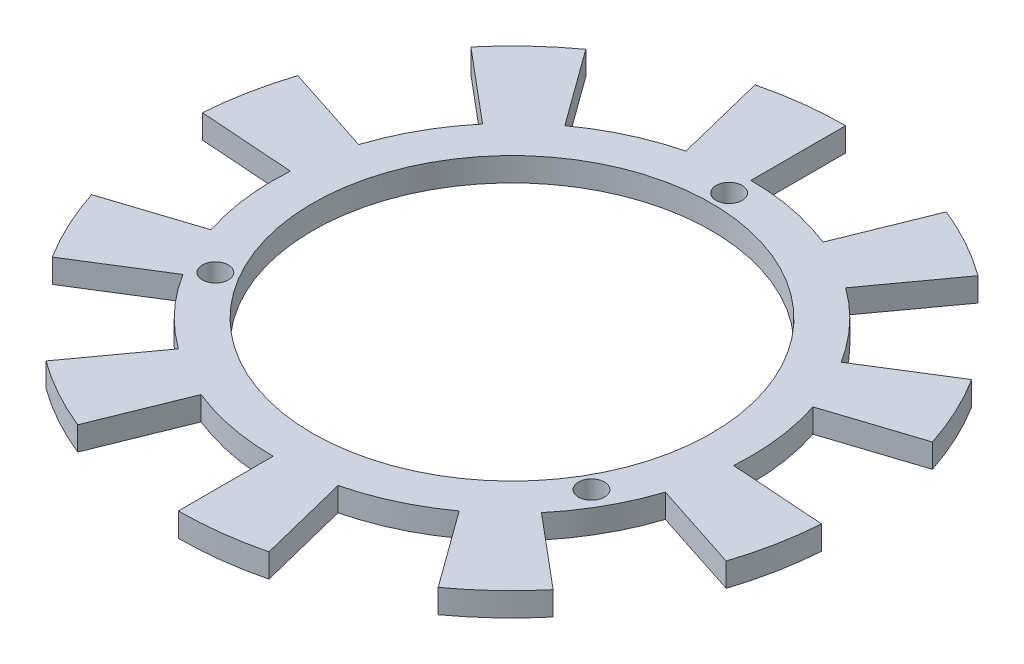
from build123d import *

# Parameters (mm, degrees)
SKETCH1_R           = 30.25
SKETCH1_R_2         = 25.25
EXTRUDE_THIN1_DEPTH = 3
SKETCH2_R           = 1.65
CUT_EXTRUDE3_DEPTH  = 10
BOSS_EXTRUDE1_DEPTH = 3


with BuildPart() as part:
    # Sketch1 → Extrude-Thin1 (new body)
    with BuildSketch(Plane(origin=(0, 0, 0), x_dir=(1, 0, 0), z_dir=(0, 1, 0))):
        Circle(SKETCH1_R)
        Circle(SKETCH1_R_2, mode=Mode.SUBTRACT)
    extrude(amount=-EXTRUDE_THIN1_DEPTH)

    # Sketch2 → Cut-Extrude3 (cut)
    with BuildSketch(Plane(origin=(0, 0, 0), x_dir=(1, 0, 0), z_dir=(0, 1, 0))):
        with Locations((0, 27.5)):
            Circle(SKETCH2_R)
        with Locations((23.815698604, -13.75)):
            Circle(SKETCH2_R)
        with Locations((-23.815698604, -13.75)):
            Circle(SKETCH2_R)
    extrude(amount=-CUT_EXTRUDE3_DEPTH, mode=Mode.SUBTRACT)

    # Sketch5 → Boss-Extrude1 (add)
    with BuildSketch(Plane.XZ.offset(3)):
        with BuildLine():
            Line((0, 42.25), (0, 30.25))
            ThreePointArc((0, 30.25), (3.686547638, 30.024521087), (7.318137342, 29.35144572))
            Line((7.318137342, 29.35144572), (10.221200089, 40.994994435))
            ThreePointArc((10.221200089, 40.994994435), (5.148979759, 41.935074907), (0, 42.25))
        make_face()
        with BuildLine():
            Line((24.833926909, 34.180968012), (17.780503882, 24.47276408))
            ThreePointArc((17.780503882, 24.47276408), (20.630450392, 22.123449474), (23.172844404, 19.444325193))
            Line((23.172844404, 19.444325193), (32.365377722, 27.157776509))
            ThreePointArc((32.365377722, 27.157776509), (28.814430713, 30.899693893), (24.833926909, 34.180968012))
        make_face()
        with BuildLine():
            Line((40.182137813, 13.055968012), (28.769459618, 9.34776408))
            ThreePointArc((28.769459618, 9.34776408), (29.694222299, 5.77197211), (30.17631252, 2.110133331))
            Line((30.17631252, 2.110133331), (42.147081123, 2.947211016))
            ThreePointArc((42.147081123, 2.947211016), (41.473748501, 8.061680055), (40.182137813, 13.055968012))
        make_face()
        with BuildLine():
            Line((40.182137813, -13.055968012), (28.769459618, -9.34776408))
            ThreePointArc((28.769459618, -9.34776408), (27.415810558, -12.784202418), (25.653454909, -16.030057743))
            Line((25.653454909, -16.030057743), (35.830032063, -22.389088914))
            ThreePointArc((35.830032063, -22.389088914), (38.291504002, -17.855621559), (40.182137813, -13.055968012))
        make_face()
        with BuildLine():
            Line((24.833926909, -34.180968012), (17.780503882, -24.47276408))
            ThreePointArc((17.780503882, -24.47276408), (14.665491012, -26.457246141), (11.331849451, -28.047311601))
            Line((11.331849451, -28.047311601), (15.827128572, -39.173517855))
            ThreePointArc((15.827128572, -39.173517855), (20.483206455, -36.952682627), (24.833926909, -34.180968012))
        make_face()
        with BuildLine():
            Line((0, -42.25), (0, -30.25))
            ThreePointArc((0, -30.25), (-3.686547638, -30.024521087), (-7.318137342, -29.35144572))
            Line((-7.318137342, -29.35144572), (-10.221200089, -40.994994435))
            ThreePointArc((-10.221200089, -40.994994435), (-5.148979759, -41.935074907), (0, -42.25))
        make_face()
        with BuildLine():
            Line((-24.833926909, -34.180968012), (-17.780503882, -24.47276408))
            ThreePointArc((-17.780503882, -24.47276408), (-20.630450392, -22.123449474), (-23.172844404, -19.444325193))
            Line((-23.172844404, -19.444325193), (-32.365377722, -27.157776509))
            ThreePointArc((-32.365377722, -27.157776509), (-28.814430713, -30.899693893), (-24.833926909, -34.180968012))
        make_face()
        with BuildLine():
            Line((-40.182137813, -13.055968012), (-28.769459618, -9.34776408))
            ThreePointArc((-28.769459618, -9.34776408), (-29.694222299, -5.77197211), (-30.17631252, -2.110133331))
            Line((-30.17631252, -2.110133331), (-42.147081123, -2.947211016))
            ThreePointArc((-42.147081123, -2.947211016), (-41.473748501, -8.061680055), (-40.182137813, -13.055968012))
        make_face()
        with BuildLine():
            Line((-40.182137813, 13.055968012), (-28.769459618, 9.34776408))
            ThreePointArc((-28.769459618, 9.34776408), (-27.415810558, 12.784202418), (-25.653454909, 16.030057743))
            Line((-25.653454909, 16.030057743), (-35.830032063, 22.389088914))
            ThreePointArc((-35.830032063, 22.389088914), (-38.291504002, 17.855621559), (-40.182137813, 13.055968012))
        make_face()
        with BuildLine():
            Line((-24.833926909, 34.180968012), (-17.780503882, 24.47276408))
            ThreePointArc((-17.780503882, 24.47276408), (-14.665491012, 26.457246141), (-11.331849451, 28.047311601))
            Line((-11.331849451, 28.047311601), (-15.827128572, 39.173517855))
            ThreePointArc((-15.827128572, 39.173517855), (-20.483206455, 36.952682627), (-24.833926909, 34.180968012))
        make_face()
    extrude(amount=-BOSS_EXTRUDE1_DEPTH)


solid = part.part
